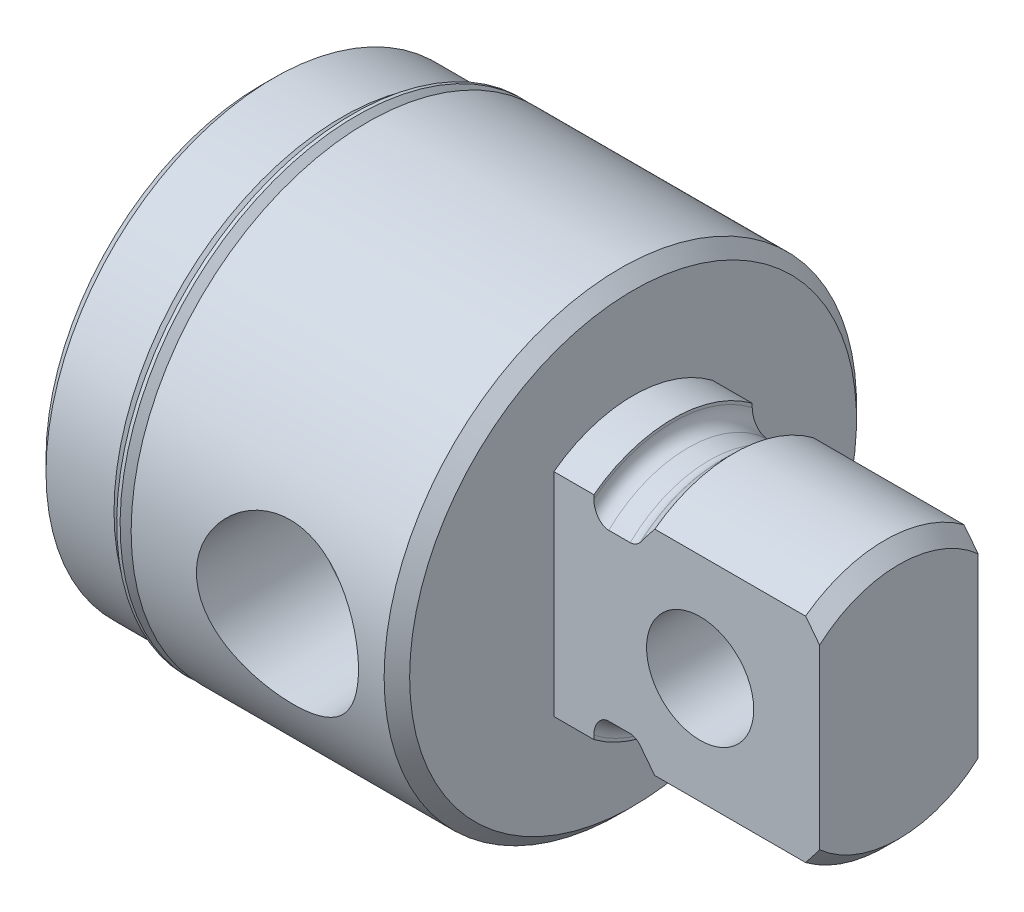
from build123d import *

# Parameters (mm, degrees)
SKETCH3_W               = 56.4388
SKETCH3_H               = 112.8776
SKETCH3_W_2             = 9.4615
SKETCH3_H_2             = 56.4388
CUT_EXTRUDE1_DEPTH      = 15.875
HOLE1_D                 = 9.525
HOLE1_DEPTH             = 20.955
HOLE1_TIP               = 2.749630657
CUT_EXTRUDE2_DEPTH      = 7.096125
CUT_EXTRUDE2_DEPTH_BACK = 7.096125
SKETCH8_R               = 3.2004


with BuildPart() as part:
    # Sketch1 → Revolve1 (revolve)
    with BuildSketch(Plane.XY):
        Polygon((0, 0), (0, 12.84605), (0.762, 13.60805), (4.826, 13.60805), (5.588, 12.84605), (6.35, 12.84605), (6.35, 14.1097), (21.463, 14.1097), (22.225, 13.3477), (22.225, 0), align=None)
    revolve(axis=Axis((22.225, 0, 0), (-1, 0, 0)))

    # Sketch2 → Revolve2 (revolve)
    with BuildSketch(Plane.XY):
        with BuildLine():
            Line((22.225, 0), (22.225, 7.90575))
            Line((22.225, 7.90575), (24.6126, 7.90575))
            Line((24.6126, 7.90575), (24.6126, 7.72795))
            ThreePointArc((24.6126, 7.72795), (24.872982072, 7.099332072), (25.5016, 6.83895))
            Line((25.5016, 6.83895), (26.7843, 6.83895))
            ThreePointArc((26.7843, 6.83895), (27.10530348, 6.898927826), (27.38299292, 7.0707683))
            Line((27.38299292, 7.0707683), (27.412917928, 7.09803))
            Line((27.412917928, 7.09803), (28.252387928, 7.9375))
            Line((28.252387928, 7.9375), (37.26053, 7.9375))
            Line((37.26053, 7.9375), (38.1, 7.09803))
            Line((38.1, 7.09803), (38.1, 0))
            Line((38.1, 0), (22.225, 0))
        make_face()
    revolve(axis=Axis((38.1, 0, 0), (-1, 0, 0)))

    # Sketch3 → Cut-Extrude1 (cut)
    with BuildSketch(Plane(origin=(38.1, 0, 0), x_dir=(0, 0, -1), z_dir=(1, 0, 0))):
        Rectangle(SKETCH3_W, SKETCH3_H)
        Rectangle(SKETCH3_W_2, SKETCH3_H_2, mode=Mode.SUBTRACT)
    extrude(amount=-CUT_EXTRUDE1_DEPTH, mode=Mode.SUBTRACT)

    # Hole1
    with Locations(Plane.ZY):
        with Locations((0, 0)):
            Hole(HOLE1_D / 2, depth=HOLE1_DEPTH)
            with Locations((0, 0, -(HOLE1_DEPTH + HOLE1_TIP / 2))):  # 120° drill point
                Cone(0, HOLE1_D / 2, HOLE1_TIP, mode=Mode.SUBTRACT)

    # Sketch6 → Cut-Revolve1 (revolve, cut)
    with BuildSketch(Plane(origin=(0, 0, 0), x_dir=(1, 0, 0), z_dir=(0, 0.9998476951563913, 0.01745240643728403))):
        Polygon((15.0876, 0), (19.710593378, 0), (19.710593378, -7.1755), (19.927075925, -14.1097), (15.0876, -14.1097), align=None)
    revolve(axis=Axis((15.0876, -0.246248219, 14.107551024), (0, 0.01745240643728403, -0.9998476951563913)), mode=Mode.SUBTRACT)

    # Sketch7 → Revolve3 (revolve)
    with BuildSketch(Plane.XY):
        with BuildLine():
            Line((5.48614893, 14.025531804), (6.227512806, 13.284167928))
            ThreePointArc((6.227512806, 13.284167928), (6.264710245, 13.194365367), (6.227512806, 13.104562806))
            Line((6.227512806, 13.104562806), (5.969, 12.84605))
            Line((5.969, 12.84605), (5.588, 12.84605))
            Line((5.588, 12.84605), (5.588, 12.59205))
            Line((5.588, 12.59205), (6.35, 12.59205))
            Line((6.35, 12.59205), (6.35, 13.44904893))
            Line((6.35, 13.44904893), (5.68934893, 14.1097))
            Line((5.68934893, 14.1097), (5.48614893, 14.1097))
            Line((5.48614893, 14.1097), (5.48614893, 14.025531804))
        make_face()
    revolve(axis=Axis((6.35, 0, 0), (-1, 0, 0)))

    # Sketch8 → Cut-Extrude2 (cut, two sides: drawn at the far end of the back side and taken through both)
    with BuildSketch(Plane.XY.offset(-CUT_EXTRUDE2_DEPTH_BACK)):
        with Locations((30.9626, 0)):
            Circle(SKETCH8_R)
    extrude(amount=CUT_EXTRUDE2_DEPTH + CUT_EXTRUDE2_DEPTH_BACK, mode=Mode.SUBTRACT)


solid = part.part
